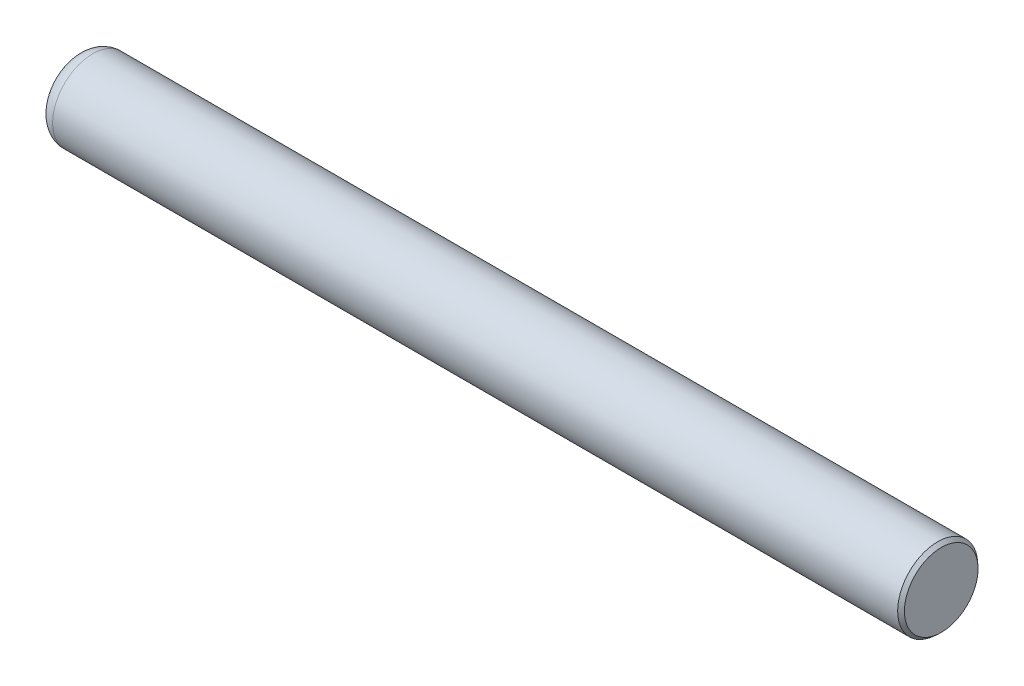
from build123d import *

# Parameters (mm, degrees)
IZIM1_W    = 540
IZIM1_H    = 25
PAH1_SIZE  = 2
PAH1_SIZE2 = 2.22122503
RADYUS1_R  = 10


with BuildPart() as part:
    # Çizim1 → Döndür1 (revolve)
    with BuildSketch(Plane.XY):
        with Locations((270, 37.5)):
            Rectangle(IZIM1_W, IZIM1_H)
    revolve(axis=Axis((0, 25, 0), (1, 0, 0)))

    # Pah1
    pah1_edges = [part.edges().sort_by_distance(p)[0] for p in [
        (540, 0, 0),
    ]]
    pah1_side = [part.faces().sort_by_distance(p)[0] for p in [
        (540, 25, 0),
    ]]
    chamfer(pah1_edges, length=PAH1_SIZE, length2=PAH1_SIZE2, reference=pah1_side[0])

    # Radyus1
    radyus1_edges = [part.edges().sort_by_distance(p)[0] for p in [
        (0, 0, 0),
    ]]
    fillet(radyus1_edges, radius=RADYUS1_R)


solid = part.part
